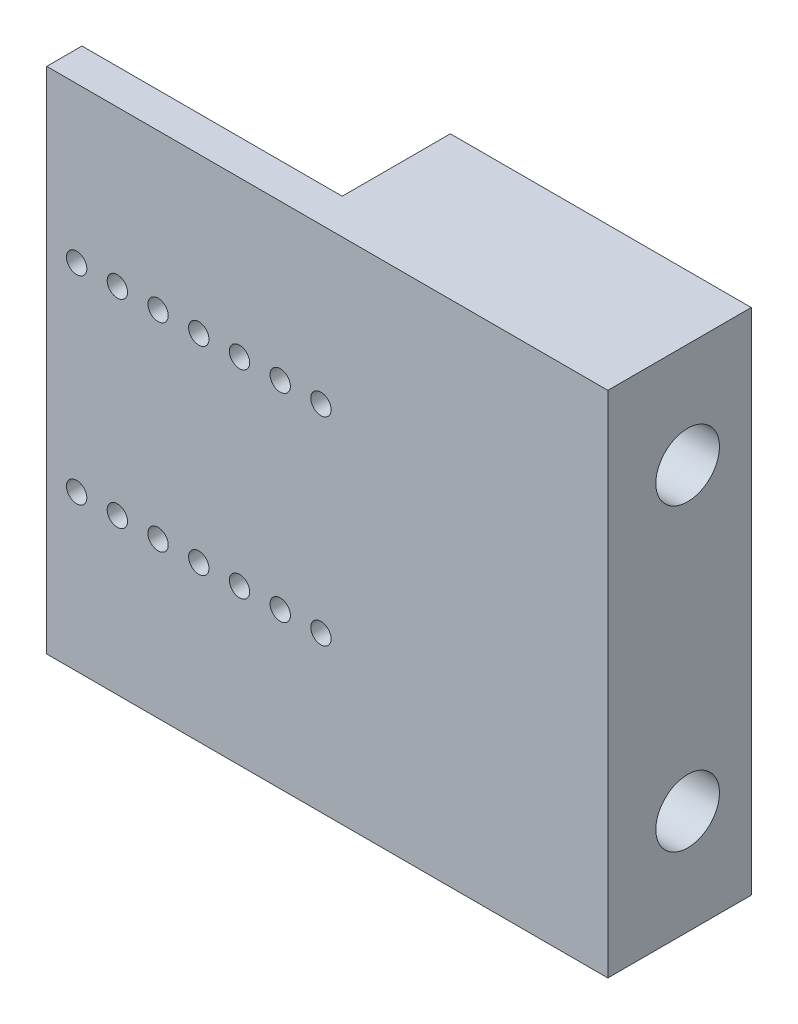
from build123d import *

# Parameters (mm, degrees)
CROQUIS1_R              = 1.6
SALIENTE_EXTRUIR3_DEPTH = 7.54
CROQUIS3_W              = 48.3
CROQUIS3_H              = 80
SALIENTE_EXTRUIR4_DEPTH = 15
CORTAR_EXTRUIR1_DEPTH   = 40.9
CROQUIS5_R              = 5
CORTAR_EXTRUIR2_DEPTH   = 54.9


with BuildPart() as part:
    # Croquis1 → Saliente-Extruir3 (new body)
    with BuildSketch(Plane.XY):
        Polygon((88.2, 0), (88.2, 37.6), (88.2, 58.8), (0, 58.8), (0, 37.6), (0, 0), (0, -21.2), (88.2, -21.2), align=None)
        with Locations((4.7, 34.4)):
            Circle(CROQUIS1_R, mode=Mode.SUBTRACT)
        with Locations((11.1, 34.4)):
            Circle(CROQUIS1_R, mode=Mode.SUBTRACT)
        with Locations((17.5, 34.4)):
            Circle(CROQUIS1_R, mode=Mode.SUBTRACT)
        with Locations((23.9, 34.4)):
            Circle(CROQUIS1_R, mode=Mode.SUBTRACT)
        with Locations((30.3, 34.4)):
            Circle(CROQUIS1_R, mode=Mode.SUBTRACT)
        with Locations((36.7, 34.4)):
            Circle(CROQUIS1_R, mode=Mode.SUBTRACT)
        with Locations((43.1, 34.4)):
            Circle(CROQUIS1_R, mode=Mode.SUBTRACT)
        with Locations((43.1, 3.2)):
            Circle(CROQUIS1_R, mode=Mode.SUBTRACT)
        with Locations((36.7, 3.2)):
            Circle(CROQUIS1_R, mode=Mode.SUBTRACT)
        with Locations((30.3, 3.2)):
            Circle(CROQUIS1_R, mode=Mode.SUBTRACT)
        with Locations((23.9, 3.2)):
            Circle(CROQUIS1_R, mode=Mode.SUBTRACT)
        with Locations((17.5, 3.2)):
            Circle(CROQUIS1_R, mode=Mode.SUBTRACT)
        with Locations((11.1, 3.2)):
            Circle(CROQUIS1_R, mode=Mode.SUBTRACT)
        with Locations((4.7, 3.2)):
            Circle(CROQUIS1_R, mode=Mode.SUBTRACT)
    extrude(amount=SALIENTE_EXTRUIR3_DEPTH)

    # Croquis3 → Saliente-Extruir4 (add)
    with BuildSketch(Plane(origin=(0, 0, 0), x_dir=(-1, 0, 0), z_dir=(0, 0, -1))):
        with Locations((-64.05, 18.8)):
            Rectangle(CROQUIS3_W, CROQUIS3_H)
    extrude(amount=SALIENTE_EXTRUIR4_DEPTH)

    # Croquis6 → Cortar-Extruir1 (cut)
    with BuildSketch(Plane.ZY):
        Polygon((0, 58.8), (2, 58.8), (2, -21.2), (0, -21.2), (-15, -21.2), (-15, 58.8), align=None)
    extrude(amount=-CORTAR_EXTRUIR1_DEPTH, mode=Mode.SUBTRACT)

    # Croquis5 → Cortar-Extruir2 (cut)
    with BuildSketch(Plane.ZY.offset(-39.9)):
        with Locations((-5, 42.36)):
            Circle(CROQUIS5_R)
        with Locations((-5, -4.76)):
            Circle(CROQUIS5_R)
    extrude(amount=-CORTAR_EXTRUIR2_DEPTH, mode=Mode.SUBTRACT)


solid = part.part
